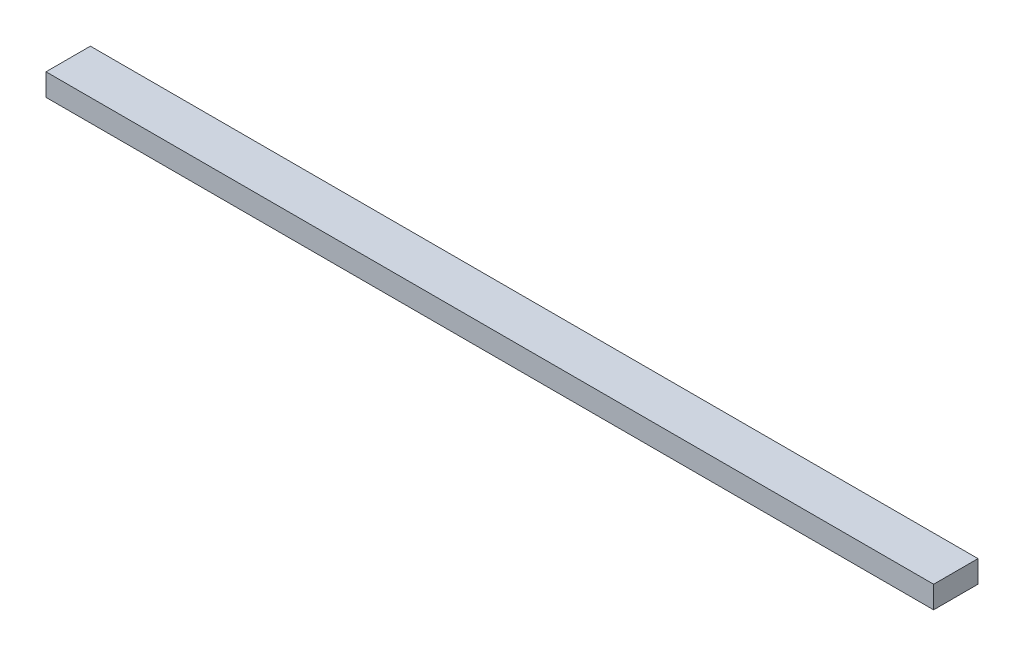
from build123d import *

# Parameters (mm, degrees)
SKETCH1_W           = 400
SKETCH1_H           = 20
BOSS_EXTRUDE1_DEPTH = 10


with BuildPart() as part:
    # Sketch1 → Boss-Extrude1 (new body)
    with BuildSketch(Plane(origin=(0, 0, 0), x_dir=(1, 0, 0), z_dir=(0, 1, 0))):
        Rectangle(SKETCH1_W, SKETCH1_H)
    extrude(amount=BOSS_EXTRUDE1_DEPTH)


solid = part.part
